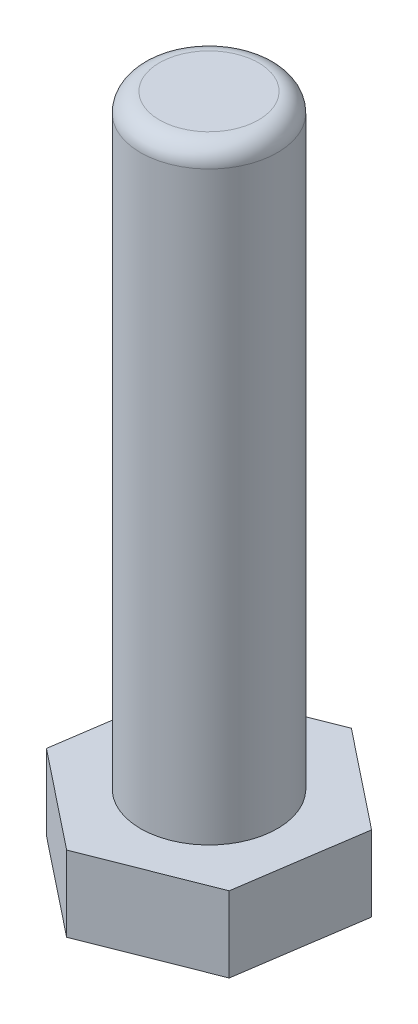
from build123d import *

# Parameters (mm, degrees)
BOSS_EXTRU_1_DEPTH = 8
ESQUISSE2_R        = 7.25
BOSS_EXTRU_2_DEPTH = 64
CONG_1_R           = 2


with BuildPart() as part:
    # Esquisse1 → Boss.-Extru.1 (new body)
    with BuildSketch(Plane(origin=(0, 0, 0), x_dir=(1, 0, 0), z_dir=(0, 1, 0))):
        Polygon((-10.392304845, 8.252712671), (-12.343211246, -4.873643664), (-1.950906401, -13.126356336), (10.392304845, -8.252712671), (12.343211246, 4.873643664), (1.950906401, 13.126356336), align=None)
    extrude(amount=BOSS_EXTRU_1_DEPTH)

    # Esquisse2 → Boss.-Extru.2 (add)
    with BuildSketch(Plane(origin=(0, 8, 0), x_dir=(1, 0, 0), z_dir=(0, 1, 0))):
        Circle(ESQUISSE2_R)
    extrude(amount=BOSS_EXTRU_2_DEPTH)

    # Congé1
    cong_1_edges = [part.edges().sort_by_distance(p)[0] for p in [
        (-7.25, 72, 0),
    ]]
    fillet(cong_1_edges, radius=CONG_1_R)


solid = part.part
